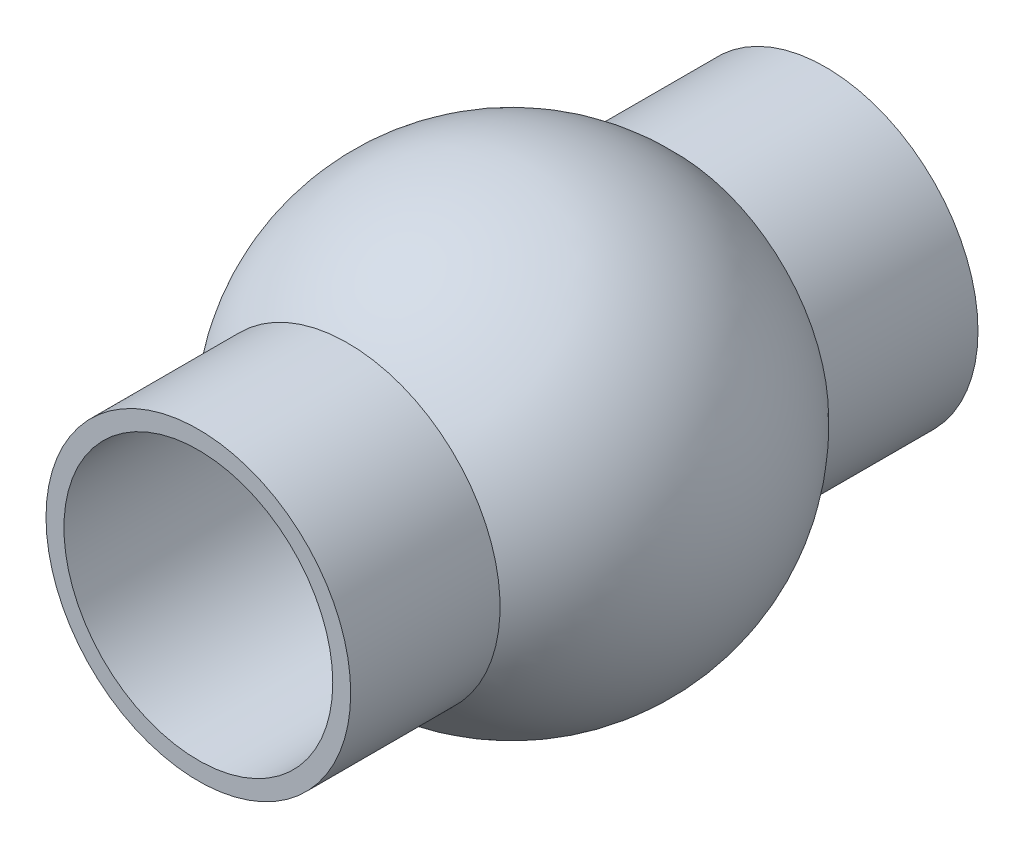
from build123d import *

# Parameters (mm, degrees)
CUT_EXTRUDE1_DEPTH      = 5.330127019
CUT_EXTRUDE1_DEPTH_BACK = 5.330127019
SKETCH2_R               = 1.5
SKETCH2_3_R             = 1.7
SKETCH2_3_R_2           = 1.5
BOSS_EXTRUDE1_DEPTH     = 3.5


with BuildPart() as part:
    # Sketch1 → Revolve1 (revolve)
    with BuildSketch(Plane.XY):
        with BuildLine():
            ThreePointArc((2.5, 0), (1.767766953, 1.767766953), (0, 2.5))
            Line((0, 2.5), (0, -2.5))
            ThreePointArc((0, -2.5), (1.767766953, -1.767766953), (2.5, 0))
        make_face()
    revolve(axis=Axis((0, 2.75, 0), (0, -1, 0)))

    # Sketch2 → Cut-Extrude1 (cut, two sides: drawn at the far end of the back side and taken through both)
    with BuildSketch(Plane.XY.offset(-CUT_EXTRUDE1_DEPTH_BACK)):
        Circle(SKETCH2_R)
    extrude(amount=CUT_EXTRUDE1_DEPTH + CUT_EXTRUDE1_DEPTH_BACK, mode=Mode.SUBTRACT)

    # Sketch2_3 → Boss-Extrude1 (add, symmetric)
    with BuildSketch(Plane.XY):
        Circle(SKETCH2_3_R)
        Circle(SKETCH2_3_R_2, mode=Mode.SUBTRACT)
    extrude(amount=BOSS_EXTRUDE1_DEPTH, both=True)


solid = part.part
